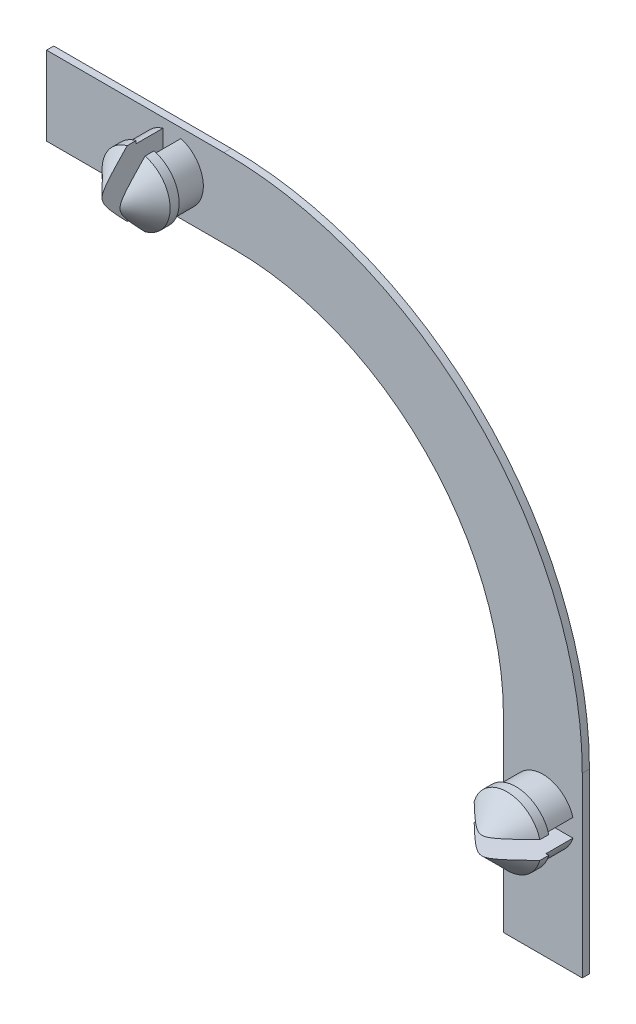
from build123d import *

# Parameters (mm, degrees)
SKICA1_W                 = 29.9
SKICA1_H                 = 4.4
SKICA1_W_2               = 4.4
SKICA1_H_2               = 25.5
P_IDAT_VYSUNUT_M1_DEPTH  = 0.4
ZAOBLIT3_R               = 15
ZAOBLIT4_R               = 20
SKICA2_R                 = 1.75
P_IDAT_VYSUNUT_M2_DEPTH  = 1.5
SKICA3_R                 = 1.9
P_IDAT_VYSUNUT_M3_DEPTH  = 2
ZKOSEN_1_SIZE            = 1.5
SKICA4_W                 = 3.8
SKICA4_H                 = 1
SKICA4_W_2               = 1
SKICA4_H_2               = 3.8
ODEBRAT_VYSUNUT_M1_DEPTH = 3.5


with BuildPart() as part:
    # Skica1 → Přidat vysunutím1 (new body)
    with BuildSketch(Plane.XY):
        with Locations((-7.066698514, 6.667743702)):
            Rectangle(SKICA1_W, SKICA1_H)
        with Locations((5.683301486, -8.282256298)):
            Rectangle(SKICA1_W_2, SKICA1_H_2)
    extrude(amount=P_IDAT_VYSUNUT_M1_DEPTH)

    # Zaoblit3
    zaoblit3_edges = [part.edges().sort_by_distance(p)[0] for p in [
        (3.483301486, 4.467743702, 0.2),
    ]]
    fillet(zaoblit3_edges, radius=ZAOBLIT3_R)

    # Zaoblit4
    zaoblit4_edges = [part.edges().sort_by_distance(p)[0] for p in [
        (7.883301486, 8.867743702, 0.2),
    ]]
    fillet(zaoblit4_edges, radius=ZAOBLIT4_R)

    # Skica2 → Přidat vysunutím2 (add)
    with BuildSketch(Plane.XY.offset(0.4)):
        with Locations((-15.016698514, 6.667743702)):
            Circle(SKICA2_R)
        with Locations((5.683301486, -14.032256298)):
            Circle(SKICA2_R)
    extrude(amount=P_IDAT_VYSUNUT_M2_DEPTH)

    # Skica3 → Přidat vysunutím3 (add)
    with BuildSketch(Plane.XY.offset(1.9)):
        with Locations((-15.016698514, 6.667743702)):
            Circle(SKICA3_R)
        with Locations((5.683301486, -14.032256298)):
            Circle(SKICA3_R)
    extrude(amount=P_IDAT_VYSUNUT_M3_DEPTH)

    # Zkosení1
    zkosen_1_edges = [part.edges().sort_by_distance(p)[0] for p in [
        (3.783301486, -14.032256298, 3.9),
        (-16.916698514, 6.667743702, 3.9),
    ]]
    chamfer(zkosen_1_edges, length=ZKOSEN_1_SIZE)

    # Skica4 → Odebrat vysunutím1 (cut)
    with BuildSketch(Plane.XY.offset(3.9)):
        with Locations((5.683301486, -14.032256298)):
            Rectangle(SKICA4_W, SKICA4_H)
        with Locations((-15.016698514, 6.667743702)):
            Rectangle(SKICA4_W_2, SKICA4_H_2)
    extrude(amount=-ODEBRAT_VYSUNUT_M1_DEPTH, mode=Mode.SUBTRACT)


solid = part.part
